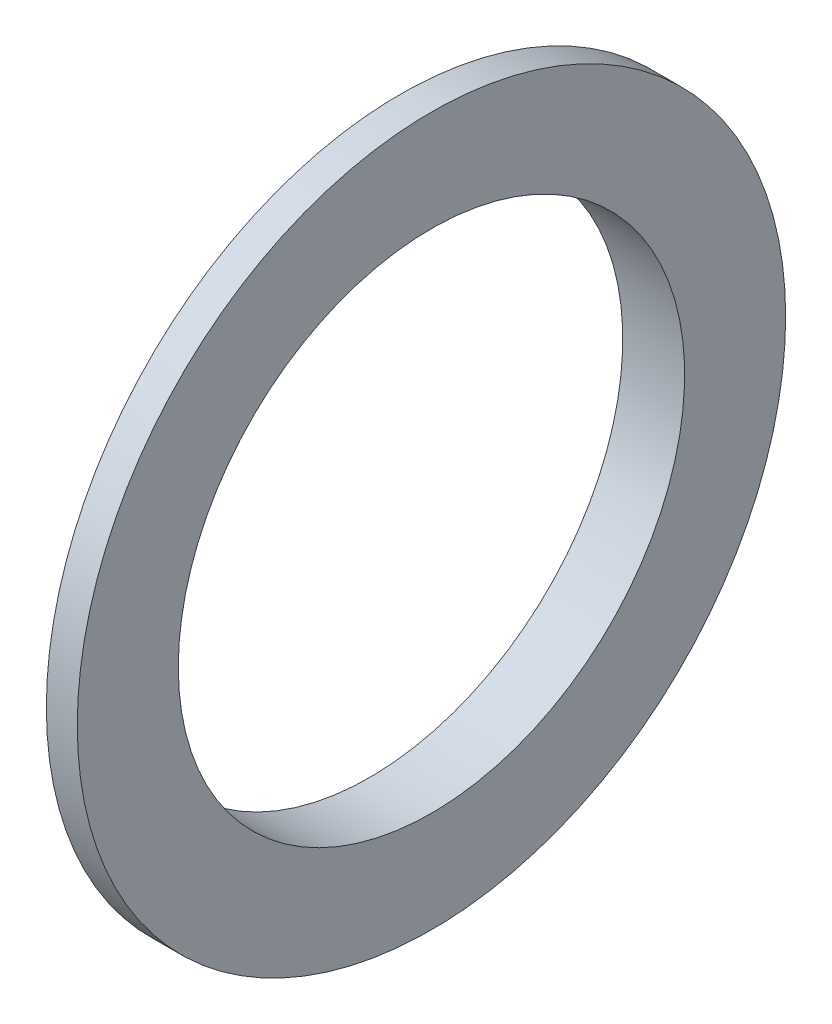
from build123d import *


with BuildPart() as part:
    # Sketch1 → Revolve1 (revolve)
    with BuildSketch(Plane(origin=(0, 0, 0), x_dir=(1, 0, 0), z_dir=(0, 1, 0))):
        Polygon((-8.735056791, 16.233067967), (-8.735056791, 8.747906619), (0, 8.747906619), (0, 23.006905401), (-4.367528396, 23.006905401), (-4.367528396, 16.233067967), align=None)
    revolve(axis=Axis((-12.067506203, 0, 26.993094599), (1, 0, 0)))


solid = part.part
